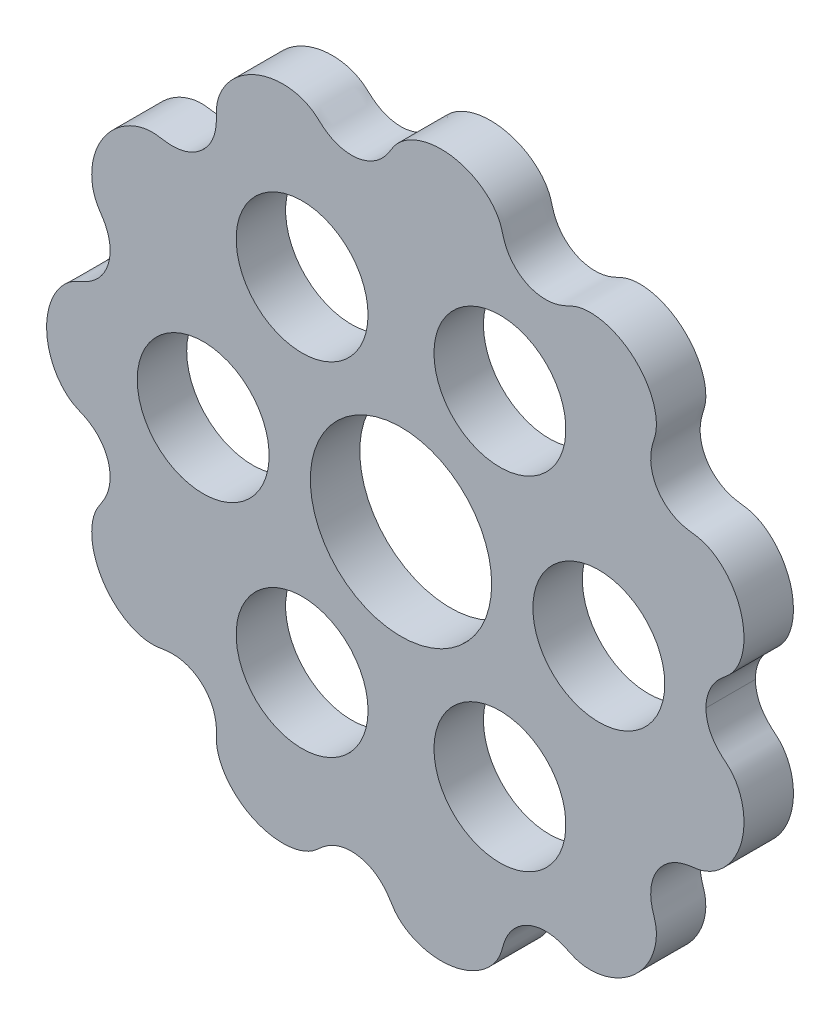
from build123d import *

# Parameters (mm, degrees)
SKETCH1_R           = 50
BOSS_EXTRUDE1_DEPTH = 6
SKETCH4_R           = 50
CUT_EXTRUDE1_DEPTH  = 71.964779997
SKETCH5_R           = 11
CUT_EXTRUDE2_DEPTH  = 61.861572058
SKETCH6_R           = 8
CUT_EXTRUDE3_DEPTH  = 61.861572058
CIRPATTERN1_COUNT   = 6


with BuildPart() as part:
    # Sketch1 → Boss-Extrude1 (new body)
    with BuildSketch(Plane.XY):
        Circle(SKETCH1_R)
    extrude(amount=-BOSS_EXTRUDE1_DEPTH)

    # Sketch4 → Cut-Extrude1 (cut, through all)
    with BuildSketch(Plane.XY):
        Circle(SKETCH4_R)
        with BuildLine():
            add(Edge.make_bspline(
                [(37, 0), (37, -0.027636852), (37.00052454, -0.082871889), (37.002884972, -0.18045134), (37.009177225, -0.318473013), (37.020968222, -0.482556817), (37.041385111, -0.669762993), (37.08371221, -0.955914581), (37.164897602, -1.331426049), (37.29493673, -1.760629462), (37.490197962, -2.233847846), (37.729641537, -2.685806897), (38.010223243, -3.11276141), (38.302284049, -3.479324057), (38.592703183, -3.791339853), (38.870763456, -4.056130423), (39.128036092, -4.281102931), (39.390812237, -4.499482219), (39.650850759, -4.721242428), (39.959984449, -5.016441433), (40.295189491, -5.403115676), (40.633033131, -5.893967276), (40.950808715, -6.494337838), (41.203631622, -7.122662872), (41.419443, -7.85489831), (41.572650905, -8.691130869), (41.635993078, -9.625921915), (41.580587547, -10.647506851), (41.404274241, -11.660053965), (41.109315346, -12.649608676), (40.697910379, -13.602035378), (40.172381935, -14.502219643), (39.490919113, -15.393053846), (38.752332543, -16.113865132), (37.992923348, -16.669703747), (37.240901206, -17.070908133), (36.681441311, -17.288158535), (36.181188889, -17.418268163), (35.753532259, -17.487839055), (35.409685854, -17.53045306), (35.066217541, -17.575337618), (34.724409172, -17.63340639), (33.962063867, -17.798973494), (32.817102334, -18.2367939), (31.691383393, -19.089839922), (30.822389034, -20.383868234), (30.408005004, -21.583410112), (30.264544857, -22.565170221), (30.296149437, -23.391940655), (30.409517015, -24.042647854), (30.533727096, -24.523006742), (30.628876748, -24.841959841), (30.729543631, -25.159141941), (30.822617888, -25.478768349), (30.91484441, -25.884738991), (30.980787588, -26.383023882), (30.994430185, -26.971735467), (30.933149437, -27.643373319), (30.802305786, -28.307364228), (30.586639634, -29.02993478), (30.267665549, -29.798302121), (29.709106138, -30.811233726), (28.794256307, -31.988518386), (27.669087784, -32.978313594), (26.379653843, -33.738471882), (25.287021126, -34.168446899), (24.466656702, -34.389481585), (23.701449959, -34.51135677), (23.089503551, -34.547942285), (22.564521607, -34.532710638), (22.049377368, -34.477852029), (21.629202945, -34.398739046), (21.220736671, -34.283828626), (20.828242791, -34.133026509), (20.52226084, -33.99370449), (20.219659457, -33.847449813), (19.914337799, -33.706833829), (19.451474603, -33.514596747), (18.81638889, -33.310013921), (17.99280957, -33.163920279), (16.989567829, -33.173920903), (15.738825948, -33.427109149), (14.340045041, -34.119653309), (13.284439876, -35.18525493), (12.683189439, -36.349823356), (12.416749821, -37.171457119), (12.300728404, -37.587252904), (12.209748848, -37.920171774), (12.076990835, -38.331082569), (11.873739183, -38.804260814), (11.576284209, -39.323076091), (11.069877257, -40.004839795), (10.227878565, -40.856815729), (8.947663165, -41.739667791), (7.176125353, -42.449567271), (5.36770379, -42.713071849), (3.809858134, -42.631487124), (2.632071227, -42.372101717), (1.821233175, -42.092655609), (1.125595745, -41.766338928), (0.541047393, -41.419405834), (-0.001818877, -41.014133865), (-0.431315608, -40.607346883), (-0.7569321, -40.221452049), (-0.996234728, -39.878560119), (-1.173608063, -39.595155372), (-1.348925043, -39.310548921), (-1.531962798, -39.030707757), (-1.82815796, -38.616831343), (-2.273656392, -38.096706551), (-2.923088726, -37.5266437), (-3.822972496, -37.00293249), (-4.803484145, -36.667560528), (-5.825475105, -36.53178309), (-6.847001043, -36.596943995), (-7.829986248, -36.85452484), (-8.594141429, -37.218630307), (-9.157159071, -37.590357642), (-9.554038995, -37.904042938), (-9.810588823, -38.124579293), (-10.061544626, -38.351292657), (-10.315517316, -38.574770425), (-10.648176501, -38.83620252), (-11.006114614, -39.067157837), (-11.3852355, -39.266163934), (-11.861057893, -39.468720975), (-12.355965237, -39.635465911), (-12.948644198, -39.777976702), (-13.716177499, -39.88423238), (-14.569329952, -39.911151096), (-15.750553482, -39.814718011), (-17.244201827, -39.446942828), (-18.890213184, -38.679946262), (-20.382044008, -37.493506011), (-21.36005784, -36.26981491), (-21.921685761, -35.202039205), (-22.178816001, -34.478050814), (-22.301395936, -33.978277453), (-22.359567533, -33.595072665), (-22.383297832, -33.335223372), (-22.395215416, -33.07464876), (-22.396760197, -32.81378416), (-22.390238245, -32.509573654), (-22.387321743, -32.161849107), (-22.397812175, -31.814088645), (-22.439261703, -31.293746666), (-22.560062058, -30.606498397), (-22.91894203, -29.52532532), (-23.639904119, -28.429800022), (-24.612144747, -27.572873119), (-25.746241795, -27.005427523), (-26.697415379, -26.734849592), (-27.518094586, -26.656780322), (-28.175813978, -26.681907027), (-28.666701043, -26.739423204), (-28.994370785, -26.78931408), (-29.321285504, -26.843428047), (-29.649847977, -26.88768008), (-30.063346129, -26.917363434), (-30.563829251, -26.907539738), (-31.145662562, -26.833441188), (-31.798294136, -26.673965931), (-32.433415164, -26.447611561), (-33.114035543, -26.129531014), (-33.824967551, -25.703399172), (-34.742505167, -25.006094121), (-35.775298152, -23.930249817), (-36.593573588, -22.670658089), (-37.160432992, -21.278283087), (-37.426604313, -20.127854979), (-37.524164124, -19.282970288), (-37.531546276, -18.510955724), (-37.478076247, -17.905928685), (-37.386746738, -17.393642972), (-37.257703238, -16.894805817), (-37.118175072, -16.49168788), (-36.944465892, -16.104492845), (-36.737012266, -15.737565722), (-36.554158676, -15.454428185), (-36.36591503, -15.175006731), (-36.183511147, -14.891602208), (-35.927538871, -14.457458685), (-35.635622587, -13.851971078), (-35.377086835, -13.049270318), (-35.251673849, -12.044547728), (-35.335182442, -10.809777627), (-35.719631236, -9.638805371), (-36.307296337, -8.713207301), (-36.972362926, -8.032467389), (-37.46690152, -7.631500174), (-37.866823939, -7.365494102), (-38.253379661, -7.150616629), (-38.617652831, -6.975432379), (-38.91331999, -6.844616693), (-39.209977881, -6.716126902), (-39.502304277, -6.577740197), (-39.820458781, -6.40222489), (-40.157483155, -6.180700535), (-40.601185119, -5.832478919), (-41.114006768, -5.325683619), (-41.63202888, -4.667063582), (-42.117159992, -3.845798061), (-42.449284298, -3.08476166), (-42.669688794, -2.408799835), (-42.794377182, -1.899921379), (-42.85992247, -1.568881911), (-42.911350752, -1.253642664), (-42.944115163, -1.0039299), (-42.969167935, -0.752869164), (-42.984776934, -0.531216439), (-42.992292188, -0.375682664), (-42.997494984, -0.214343188), (-42.99942192, -0.108980609), (-43, -0.043430185), (-43, 0)],
                knots=[0.068010482, 0.068010482, 0.068010482, 0.068010482, 0.068010482, 0.068750499, 0.069490515, 0.070230532, 0.070970548, 0.072450581, 0.073930614, 0.076890681, 0.079850747, 0.082799281, 0.085747815, 0.08869635, 0.091644884, 0.093619673, 0.095594461, 0.097569249, 0.099544037, 0.101518826, 0.103493614, 0.107443191, 0.111350981, 0.115258771, 0.119166561, 0.123074351, 0.128973109, 0.134871866, 0.140770623, 0.146669381, 0.152678776, 0.158688171, 0.164697566, 0.17070696, 0.178536419, 0.182451148, 0.186365877, 0.190370415, 0.192372684, 0.194374953, 0.196377221, 0.19837949, 0.200381759, 0.202384028, 0.214411566, 0.22646627, 0.232172718, 0.237879166, 0.243575835, 0.249272504, 0.251195875, 0.253119246, 0.255042616, 0.256965987, 0.258889358, 0.260812729, 0.26465947, 0.268564315, 0.27246916, 0.276374005, 0.28027885, 0.285971675, 0.291664501, 0.303050152, 0.314568051, 0.320327001, 0.326085951, 0.330128136, 0.334170321, 0.338212506, 0.340233598, 0.342254691, 0.346139712, 0.348082222, 0.350024733, 0.351967243, 0.353909754, 0.355852264, 0.357794775, 0.363549736, 0.369304697, 0.375079832, 0.380854967, 0.392867901, 0.404851458, 0.408841647, 0.410836742, 0.412831836, 0.414826931, 0.416822026, 0.420812215, 0.424713173, 0.428614131, 0.436416048, 0.448391985, 0.460367923, 0.472309499, 0.478280286, 0.484251074, 0.488172992, 0.49209491, 0.496016828, 0.499938746, 0.50380279, 0.505734812, 0.507666834, 0.509598856, 0.511530878, 0.5134629, 0.515394921, 0.521360952, 0.527326982, 0.533319355, 0.539311727, 0.545159739, 0.551007751, 0.556834598, 0.562661445, 0.564616203, 0.566570961, 0.568525719, 0.570480477, 0.572435235, 0.574389993, 0.578299509, 0.580309179, 0.582318849, 0.586338189, 0.590357528, 0.594376868, 0.600204081, 0.606031294, 0.61768572, 0.629747248, 0.641808775, 0.649665786, 0.653594292, 0.657522797, 0.659532533, 0.661542268, 0.662547136, 0.663552003, 0.665561738, 0.667571474, 0.669581209, 0.671590944, 0.67360068, 0.679635047, 0.685669415, 0.697765914, 0.703452587, 0.70913926, 0.714817222, 0.720495184, 0.72241044, 0.724325696, 0.726240952, 0.728156208, 0.730071464, 0.731986721, 0.735817233, 0.739707707, 0.743598181, 0.747488655, 0.751379129, 0.757050969, 0.762722809, 0.77406649, 0.785678715, 0.791484828, 0.797290941, 0.801295932, 0.805300923, 0.809305914, 0.811308409, 0.813310905, 0.817205682, 0.81915307, 0.821100459, 0.823047847, 0.824995236, 0.826942624, 0.828890013, 0.834695874, 0.840501736, 0.846328745, 0.852155755, 0.863130941, 0.868612127, 0.871352721, 0.874093314, 0.877830235, 0.879698696, 0.881567156, 0.883435617, 0.885304078, 0.887172538, 0.889040999, 0.891829168, 0.894617336, 0.900193674, 0.905665509, 0.911137344, 0.91660918, 0.919345097, 0.922081015, 0.923243921, 0.924406826, 0.926732638, 0.927895544, 0.929058449, 0.929639902, 0.930221355, 0.931384261, 0.931384261, 0.931384261, 0.931384261, 0.931384261], degree=4))
            add(Edge.make_bspline(
                [(37, 0), (37, 0.027636852), (37.00052454, 0.082871889), (37.002884972, 0.18045134), (37.009177225, 0.318473013), (37.020968222, 0.482556817), (37.041385111, 0.669762993), (37.08371221, 0.955914581), (37.164897602, 1.331426049), (37.29493673, 1.760629462), (37.490197962, 2.233847846), (37.729641537, 2.685806897), (38.010223243, 3.11276141), (38.302284049, 3.479324057), (38.592703183, 3.791339853), (38.870763456, 4.056130423), (39.128036092, 4.281102931), (39.390812237, 4.499482219), (39.650850759, 4.721242428), (39.959984449, 5.016441433), (40.295189491, 5.403115676), (40.633033131, 5.893967276), (40.950808715, 6.494337838), (41.203631622, 7.122662872), (41.419443, 7.85489831), (41.572650905, 8.691130869), (41.635993078, 9.625921915), (41.580587547, 10.647506851), (41.404274241, 11.660053965), (41.109315346, 12.649608676), (40.697910379, 13.602035378), (40.172381935, 14.502219643), (39.490919113, 15.393053846), (38.752332543, 16.113865132), (37.992923348, 16.669703747), (37.240901206, 17.070908133), (36.681441311, 17.288158535), (36.181188889, 17.418268163), (35.753532259, 17.487839055), (35.409685854, 17.53045306), (35.066217541, 17.575337618), (34.724409172, 17.63340639), (33.962063867, 17.798973494), (32.817102334, 18.2367939), (31.691383393, 19.089839922), (30.822389034, 20.383868234), (30.408005004, 21.583410112), (30.264544857, 22.565170221), (30.296149437, 23.391940655), (30.409517015, 24.042647854), (30.533727096, 24.523006742), (30.628876748, 24.841959841), (30.729543631, 25.159141941), (30.822617888, 25.478768349), (30.91484441, 25.884738991), (30.980787588, 26.383023882), (30.994430185, 26.971735467), (30.933149437, 27.643373319), (30.802305786, 28.307364228), (30.586639634, 29.02993478), (30.267665549, 29.798302121), (29.709106138, 30.811233726), (28.794256307, 31.988518386), (27.669087784, 32.978313594), (26.379653843, 33.738471882), (25.287021126, 34.168446899), (24.466656702, 34.389481585), (23.701449959, 34.51135677), (23.089503551, 34.547942285), (22.564521607, 34.532710638), (22.049377368, 34.477852029), (21.629202945, 34.398739046), (21.220736671, 34.283828626), (20.828242791, 34.133026509), (20.52226084, 33.99370449), (20.219659457, 33.847449813), (19.914337799, 33.706833829), (19.451474603, 33.514596747), (18.81638889, 33.310013921), (17.99280957, 33.163920279), (16.989567829, 33.173920903), (15.738825948, 33.427109149), (14.340045041, 34.119653309), (13.284439876, 35.18525493), (12.683189439, 36.349823356), (12.416749821, 37.171457119), (12.300728404, 37.587252904), (12.209748848, 37.920171774), (12.076990835, 38.331082569), (11.873739183, 38.804260814), (11.576284209, 39.323076091), (11.069877257, 40.004839795), (10.227878565, 40.856815729), (8.947663165, 41.739667791), (7.176125353, 42.449567271), (5.36770379, 42.713071849), (3.809858134, 42.631487124), (2.632071227, 42.372101717), (1.821233175, 42.092655609), (1.125595745, 41.766338928), (0.541047393, 41.419405834), (-0.001818877, 41.014133865), (-0.431315608, 40.607346883), (-0.7569321, 40.221452049), (-0.996234728, 39.878560119), (-1.173608063, 39.595155372), (-1.348925043, 39.310548921), (-1.531962798, 39.030707757), (-1.82815796, 38.616831343), (-2.273656392, 38.096706551), (-2.923088726, 37.5266437), (-3.822972496, 37.00293249), (-4.803484145, 36.667560528), (-5.825475105, 36.53178309), (-6.847001043, 36.596943995), (-7.829986248, 36.85452484), (-8.594141429, 37.218630307), (-9.157159071, 37.590357642), (-9.554038995, 37.904042938), (-9.810588823, 38.124579293), (-10.061544626, 38.351292657), (-10.315517316, 38.574770425), (-10.648176501, 38.83620252), (-11.006114614, 39.067157837), (-11.3852355, 39.266163934), (-11.861057893, 39.468720975), (-12.355965237, 39.635465911), (-12.948644198, 39.777976702), (-13.716177499, 39.88423238), (-14.569329952, 39.911151096), (-15.750553482, 39.814718011), (-17.244201827, 39.446942828), (-18.890213184, 38.679946262), (-20.382044008, 37.493506011), (-21.36005784, 36.26981491), (-21.921685761, 35.202039205), (-22.178816001, 34.478050814), (-22.301395936, 33.978277453), (-22.359567533, 33.595072665), (-22.383297832, 33.335223372), (-22.395215416, 33.07464876), (-22.396760197, 32.81378416), (-22.390238245, 32.509573654), (-22.387321743, 32.161849107), (-22.397812175, 31.814088645), (-22.439261703, 31.293746666), (-22.560062058, 30.606498397), (-22.91894203, 29.52532532), (-23.639904119, 28.429800022), (-24.612144747, 27.572873119), (-25.746241795, 27.005427523), (-26.697415379, 26.734849592), (-27.518094586, 26.656780322), (-28.175813978, 26.681907027), (-28.666701043, 26.739423204), (-28.994370785, 26.78931408), (-29.321285504, 26.843428047), (-29.649847977, 26.88768008), (-30.063346129, 26.917363434), (-30.563829251, 26.907539738), (-31.145662562, 26.833441188), (-31.798294136, 26.673965931), (-32.433415164, 26.447611561), (-33.114035543, 26.129531014), (-33.824967551, 25.703399172), (-34.742505167, 25.006094121), (-35.775298152, 23.930249817), (-36.593573588, 22.670658089), (-37.160432992, 21.278283087), (-37.426604313, 20.127854979), (-37.524164124, 19.282970288), (-37.531546276, 18.510955724), (-37.478076247, 17.905928685), (-37.386746738, 17.393642972), (-37.257703238, 16.894805817), (-37.118175072, 16.49168788), (-36.944465892, 16.104492845), (-36.737012266, 15.737565722), (-36.554158676, 15.454428185), (-36.36591503, 15.175006731), (-36.183511147, 14.891602208), (-35.927538871, 14.457458685), (-35.635622587, 13.851971078), (-35.377086835, 13.049270318), (-35.251673849, 12.044547728), (-35.335182442, 10.809777627), (-35.719631236, 9.638805371), (-36.307296337, 8.713207301), (-36.972362926, 8.032467389), (-37.46690152, 7.631500174), (-37.866823939, 7.365494102), (-38.253379661, 7.150616629), (-38.617652831, 6.975432379), (-38.91331999, 6.844616693), (-39.209977881, 6.716126902), (-39.502304277, 6.577740197), (-39.820458781, 6.40222489), (-40.157483155, 6.180700535), (-40.601185119, 5.832478919), (-41.114006768, 5.325683619), (-41.63202888, 4.667063582), (-42.117159992, 3.845798061), (-42.449284298, 3.08476166), (-42.669688794, 2.408799835), (-42.794377182, 1.899921379), (-42.85992247, 1.568881911), (-42.911350752, 1.253642664), (-42.944115163, 1.0039299), (-42.969167935, 0.752869164), (-42.984776934, 0.531216439), (-42.992292188, 0.375682664), (-42.997494984, 0.214343188), (-42.99942192, 0.108980609), (-43, 0.043430185), (-43, 0)],
                knots=[0.068010482, 0.068010482, 0.068010482, 0.068010482, 0.068010482, 0.068750499, 0.069490515, 0.070230532, 0.070970548, 0.072450581, 0.073930614, 0.076890681, 0.079850747, 0.082799281, 0.085747815, 0.08869635, 0.091644884, 0.093619673, 0.095594461, 0.097569249, 0.099544037, 0.101518826, 0.103493614, 0.107443191, 0.111350981, 0.115258771, 0.119166561, 0.123074351, 0.128973109, 0.134871866, 0.140770623, 0.146669381, 0.152678776, 0.158688171, 0.164697566, 0.17070696, 0.178536419, 0.182451148, 0.186365877, 0.190370415, 0.192372684, 0.194374953, 0.196377221, 0.19837949, 0.200381759, 0.202384028, 0.214411566, 0.22646627, 0.232172718, 0.237879166, 0.243575835, 0.249272504, 0.251195875, 0.253119246, 0.255042616, 0.256965987, 0.258889358, 0.260812729, 0.26465947, 0.268564315, 0.27246916, 0.276374005, 0.28027885, 0.285971675, 0.291664501, 0.303050152, 0.314568051, 0.320327001, 0.326085951, 0.330128136, 0.334170321, 0.338212506, 0.340233598, 0.342254691, 0.346139712, 0.348082222, 0.350024733, 0.351967243, 0.353909754, 0.355852264, 0.357794775, 0.363549736, 0.369304697, 0.375079832, 0.380854967, 0.392867901, 0.404851458, 0.408841647, 0.410836742, 0.412831836, 0.414826931, 0.416822026, 0.420812215, 0.424713173, 0.428614131, 0.436416048, 0.448391985, 0.460367923, 0.472309499, 0.478280286, 0.484251074, 0.488172992, 0.49209491, 0.496016828, 0.499938746, 0.50380279, 0.505734812, 0.507666834, 0.509598856, 0.511530878, 0.5134629, 0.515394921, 0.521360952, 0.527326982, 0.533319355, 0.539311727, 0.545159739, 0.551007751, 0.556834598, 0.562661445, 0.564616203, 0.566570961, 0.568525719, 0.570480477, 0.572435235, 0.574389993, 0.578299509, 0.580309179, 0.582318849, 0.586338189, 0.590357528, 0.594376868, 0.600204081, 0.606031294, 0.61768572, 0.629747248, 0.641808775, 0.649665786, 0.653594292, 0.657522797, 0.659532533, 0.661542268, 0.662547136, 0.663552003, 0.665561738, 0.667571474, 0.669581209, 0.671590944, 0.67360068, 0.679635047, 0.685669415, 0.697765914, 0.703452587, 0.70913926, 0.714817222, 0.720495184, 0.72241044, 0.724325696, 0.726240952, 0.728156208, 0.730071464, 0.731986721, 0.735817233, 0.739707707, 0.743598181, 0.747488655, 0.751379129, 0.757050969, 0.762722809, 0.77406649, 0.785678715, 0.791484828, 0.797290941, 0.801295932, 0.805300923, 0.809305914, 0.811308409, 0.813310905, 0.817205682, 0.81915307, 0.821100459, 0.823047847, 0.824995236, 0.826942624, 0.828890013, 0.834695874, 0.840501736, 0.846328745, 0.852155755, 0.863130941, 0.868612127, 0.871352721, 0.874093314, 0.877830235, 0.879698696, 0.881567156, 0.883435617, 0.885304078, 0.887172538, 0.889040999, 0.891829168, 0.894617336, 0.900193674, 0.905665509, 0.911137344, 0.91660918, 0.919345097, 0.922081015, 0.923243921, 0.924406826, 0.926732638, 0.927895544, 0.929058449, 0.929639902, 0.930221355, 0.931384261, 0.931384261, 0.931384261, 0.931384261, 0.931384261], degree=4))
        make_face(mode=Mode.SUBTRACT)
    extrude(amount=-CUT_EXTRUDE1_DEPTH, mode=Mode.SUBTRACT)

    # Sketch5 → Cut-Extrude2 (cut, through all)
    with BuildSketch(Plane.XY):
        Circle(SKETCH5_R)
    extrude(amount=-CUT_EXTRUDE2_DEPTH, mode=Mode.SUBTRACT)

    # Sketch6 → Cut-Extrude3 (cut, through all)
    with BuildSketch(Plane.XY):
        with Locations((24, 0)):
            Circle(SKETCH6_R)
    cut_extrude3 = extrude(amount=-CUT_EXTRUDE3_DEPTH, mode=Mode.SUBTRACT)

    # CirPattern1: Cut-Extrude3 ×6 about axis
    cirpattern1_axis = Axis((0, 0, 0), (0, 0, 1))
    for i in range(1, CIRPATTERN1_COUNT):
        add(cut_extrude3.rotate(cirpattern1_axis, i * 360 / CIRPATTERN1_COUNT), mode=Mode.SUBTRACT)


solid = part.part
